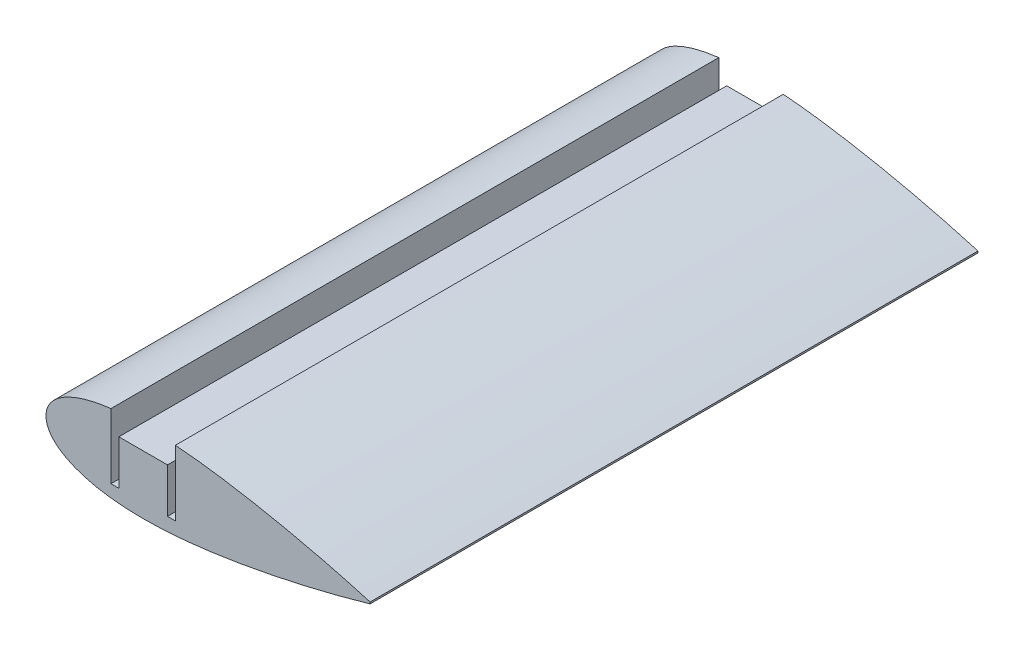
from build123d import *

# Parameters (mm, degrees)
BOSS_EXTRUDE1_DEPTH = 150
CUT_EXTRUDE1_REACH  = 152


with BuildPart() as part:
    # Sketch2 → Boss-Extrude1 (new body)
    with BuildSketch(Plane.XY):
        with BuildLine():
            Line((55.998991919, 0.209938863), (55.998991919, -0.209938863))
            add(Edge.make_bspline(
                [(55.998991919, 0.209938863), (53.463896497, 0.950455214), (48.803904258, 2.233873897), (42.428923908, 3.819934884), (36.743376831, 5.120873453), (31.199749362, 6.287249396), (25.282426203, 7.407488419), (20.176484373, 8.245231015), (14.979623954, 8.974887306), (10.821499069, 9.44862332), (6.697350987, 9.777022894), (3.680655604, 9.939622605), (0.739619613, 10.012665726), (-2.107751213, 9.990028944), (-4.843941705, 9.866960982), (-7.452188048, 9.640899897), (-9.916478705, 9.310630744), (-12.221751766, 8.877222993), (-14.354021752, 8.343659433), (-16.300401345, 7.714341159), (-18.049355518, 6.995399514), (-19.590605164, 6.19339349), (-20.915410238, 5.315562027), (-22.015853697, 4.368064829), (-22.884921184, 3.356491652), (-23.514451457, 2.28497611), (-23.895372624, 1.158788991), (-24.018679664, 0), (-23.895372624, -1.158788991), (-23.514451457, -2.28497611), (-22.884921184, -3.356491652), (-22.015853697, -4.368064829), (-20.915410238, -5.315562027), (-19.590605164, -6.19339349), (-18.049355518, -6.995399514), (-16.300401345, -7.714341159), (-14.354021752, -8.343659433), (-12.221751766, -8.877222993), (-9.916478705, -9.310630744), (-7.452188048, -9.640899897), (-4.843941705, -9.866960982), (-2.107751213, -9.990028944), (0.739619613, -10.012665726), (3.680655604, -9.939622605), (7.74070187, -9.72078634), (12.912832982, -9.241334238), (19.136671313, -8.415754469), (25.28242537, -7.407448977), (31.199752667, -6.287252304), (37.517160947, -4.95809922), (44.742570872, -3.275857272), (51.057566095, -1.626260629), (54.945025722, -0.517808616), (55.95791152, -0.221938691), (55.998991919, -0.209938863)],
                knots=[0, 0, 0, 0, 0.046554703, 0.085193372, 0.115793222, 0.149362634, 0.18504799, 0.221946042, 0.240561295, 0.277549679, 0.295701185, 0.31348255, 0.330796889, 0.347551895, 0.363665842, 0.379065349, 0.393686065, 0.407475418, 0.420391934, 0.432405657, 0.443502806, 0.453686421, 0.462984388, 0.471455944, 0.479204465, 0.486388269, 0.493228974, 0.5, 0.506771026, 0.513611731, 0.520795535, 0.528544056, 0.537015612, 0.546313579, 0.556497194, 0.567594343, 0.579608066, 0.592524582, 0.606313935, 0.620934651, 0.636334158, 0.652448105, 0.669203111, 0.68651745, 0.704298815, 0.740866341, 0.778053958, 0.81495201, 0.850637366, 0.884206778, 0.928744289, 0.981399281, 0.999245596, 1, 1, 1, 1], degree=3))
        make_face()
    extrude(amount=BOSS_EXTRUDE1_DEPTH)

    # Sketch3 → Cut-Extrude1 (cut, up to next)
    with BuildSketch(Plane(origin=(0, 0, 0), x_dir=(-1, 0, 0), z_dir=(0, 0, -1)), mode=Mode.PRIVATE) as cut_extrude1_sk1:
        with BuildLine():
            Line((6, -6.5), (7.95, -6.5))
            Line((7.95, -6.5), (7.95, 9.56370057))
            add(Edge.make_bspline(
                [(-7.95, 9.673763928), (-7.525333967, 9.706496284), (-6.094337758, 9.809525273), (-3.680655604, 9.939622605), (-0.739619613, 10.012665726), (2.107751213, 9.990028944), (4.843941705, 9.866960982), (6.778071836, 9.69932668), (7.798061571, 9.581867182), (7.95, 9.56370057)],
                knots=[0.28819337, 0.28819337, 0.28819337, 0.28819337, 0.295701185, 0.31348255, 0.330796889, 0.347551895, 0.363665842, 0.379065349, 0.381762425, 0.381762425, 0.381762425, 0.381762425], degree=3))
            Line((-7.95, 9.673763928), (-7.95, -6.5))
            Line((-7.95, -6.5), (-6, -6.5))
            Line((-6, -6.5), (-6, 4.5))
            Line((-6, 4.5), (6, 4.5))
            Line((6, 4.5), (6, -6.5))
        make_face()
    cut_extrude1_tool1 = extrude(cut_extrude1_sk1.sketch, amount=-CUT_EXTRUDE1_REACH, mode=Mode.PRIVATE) & part.part
    add(cut_extrude1_tool1.solids().sort_by_distance((-6.975, -6.270858, 0))[0], mode=Mode.SUBTRACT)


solid = part.part
